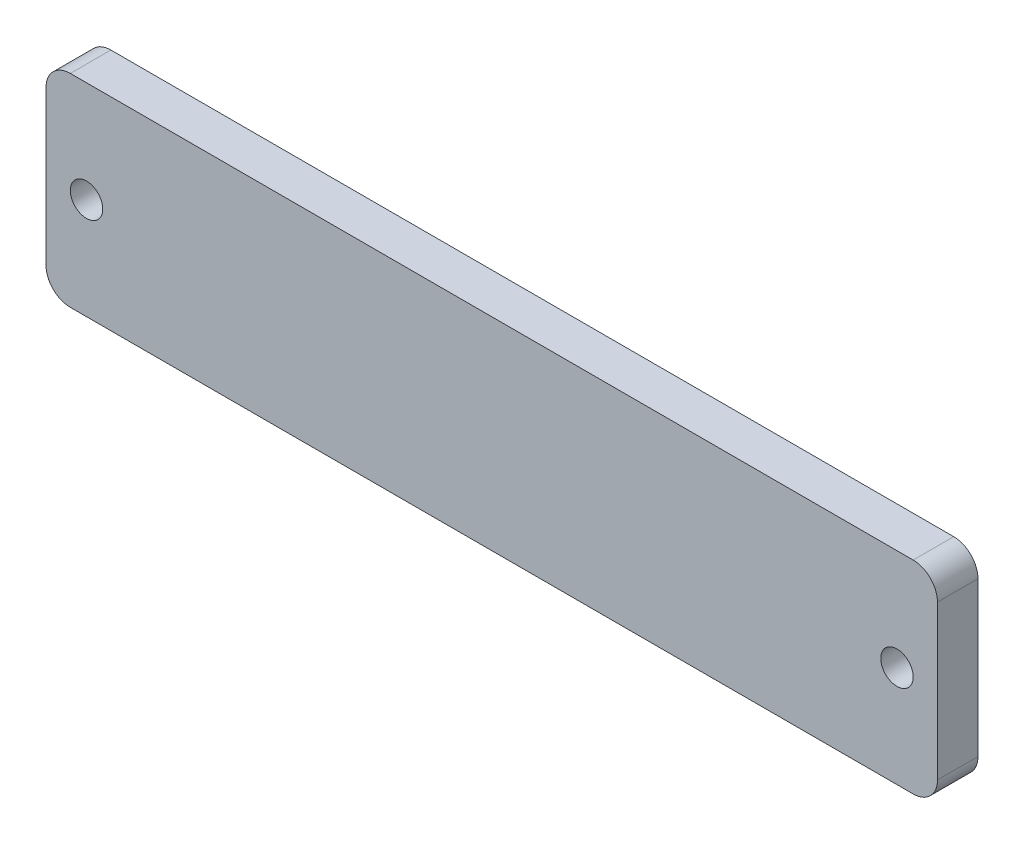
from build123d import *

# Parameters (mm, degrees)
EXTRUDE_1_DEPTH     = 5
SKETCH_2_R          = 2
CUT_EXTRUDE_1_DEPTH = 6


with BuildPart() as part:
    # 草图1 → 凸台-拉伸1 (new body)
    with BuildSketch(Plane.XY):
        with BuildLine():
            Line((-52, 12.5), (52, 12.5))
            ThreePointArc((52, 12.5), (54.121320344, 11.621320344), (55, 9.5))
            Line((55, 9.5), (55, -9.5))
            ThreePointArc((55, -9.5), (54.121320344, -11.621320344), (52, -12.5))
            Line((52, -12.5), (-52, -12.5))
            ThreePointArc((-52, -12.5), (-54.121320344, -11.621320344), (-55, -9.5))
            Line((-55, -9.5), (-55, 9.5))
            ThreePointArc((-55, 9.5), (-54.121320344, 11.621320344), (-52, 12.5))
        make_face()
    extrude(amount=-EXTRUDE_1_DEPTH)

    # 草图2 → 切除-拉伸1 (cut, through all)
    with BuildSketch(Plane.XY):
        with Locations((50, 0)):
            Circle(SKETCH_2_R)
        with Locations((-50, 0)):
            Circle(SKETCH_2_R)
    extrude(amount=-CUT_EXTRUDE_1_DEPTH, mode=Mode.SUBTRACT)


solid = part.part
